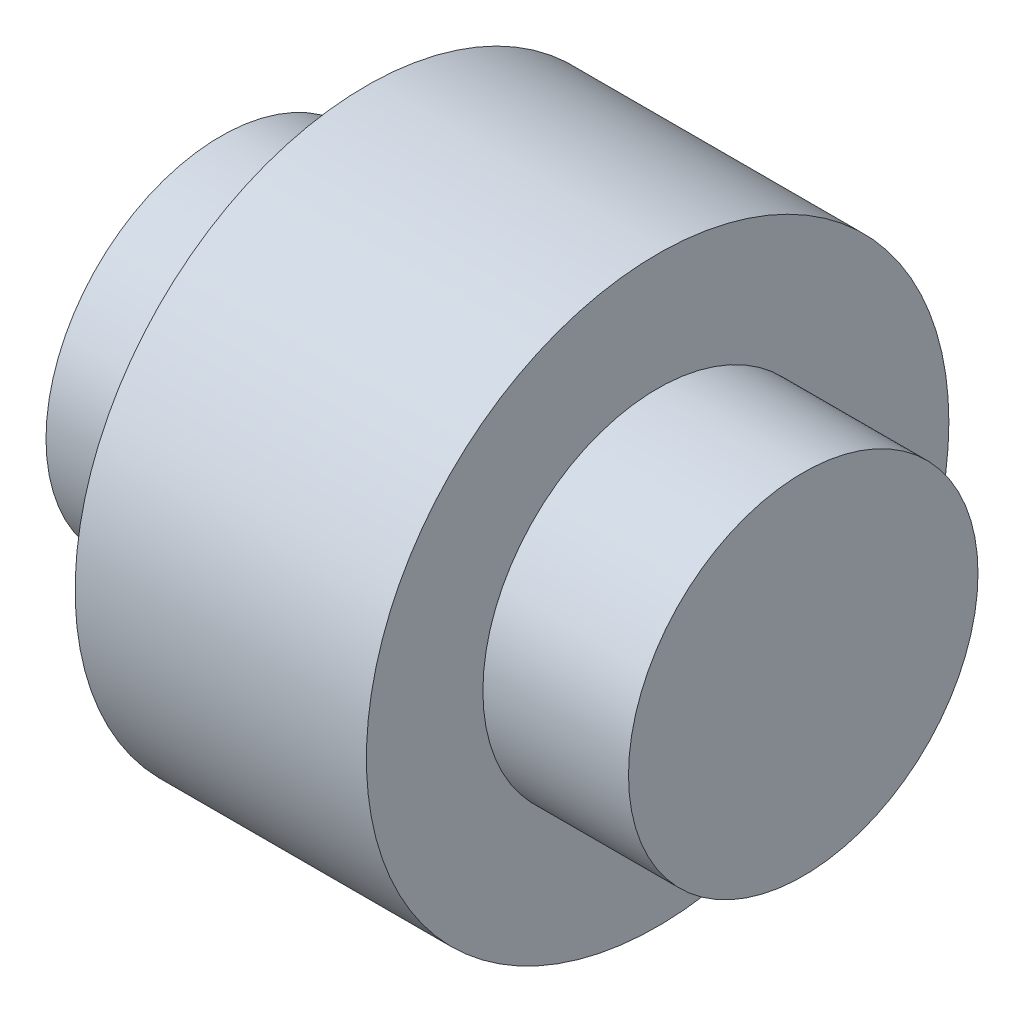
from build123d import *

# Parameters (mm, degrees)
SKETCH1_R           = 7.62
BOSS_EXTRUDE1_DEPTH = 25.4
SKETCH2_R           = 12.7
BOSS_EXTRUDE2_DEPTH = 6.35


with BuildPart() as part:
    # Sketch1 → Boss-Extrude1 (new body)
    with BuildSketch(Plane(origin=(0, 0, 0), x_dir=(0, 0, -1), z_dir=(1, 0, 0))):
        Circle(SKETCH1_R)
    extrude(amount=-BOSS_EXTRUDE1_DEPTH)

    # Sketch2 → Boss-Extrude2 (add, symmetric)
    with BuildSketch(Plane(origin=(-12.7, 0, 0), x_dir=(0, 0, -1), z_dir=(1, 0, 0))):
        Circle(SKETCH2_R)
    extrude(amount=BOSS_EXTRUDE2_DEPTH, both=True)


solid = part.part
